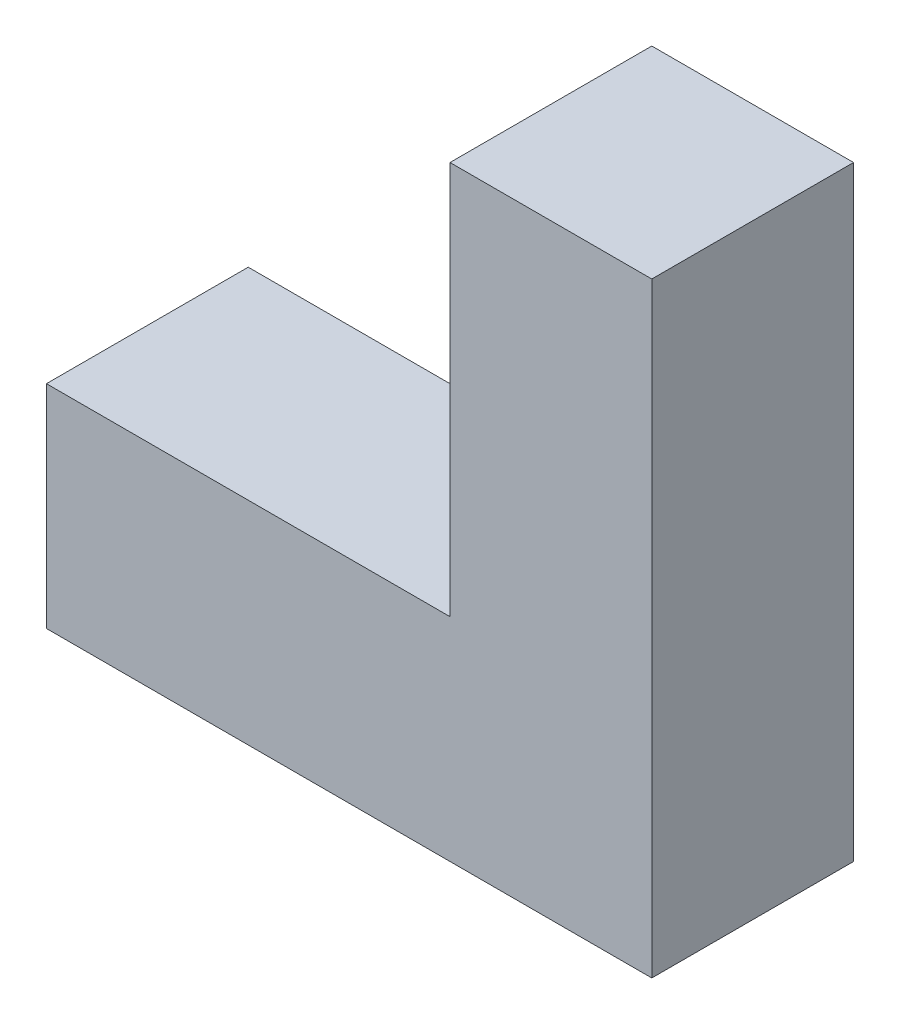
from build123d import *

# Parameters (mm, degrees)
BOSS_EXTRUDE1_DEPTH = 15


with BuildPart() as part:
    # Sketch1 → Boss-Extrude1 (new body)
    with BuildSketch(Plane.XY):
        Polygon((0, 0), (15, 0), (15, 45), (0, 45), (0, 15.76142132), (-30, 15.76142132), (-30, 0), align=None)
    extrude(amount=BOSS_EXTRUDE1_DEPTH)


solid = part.part
